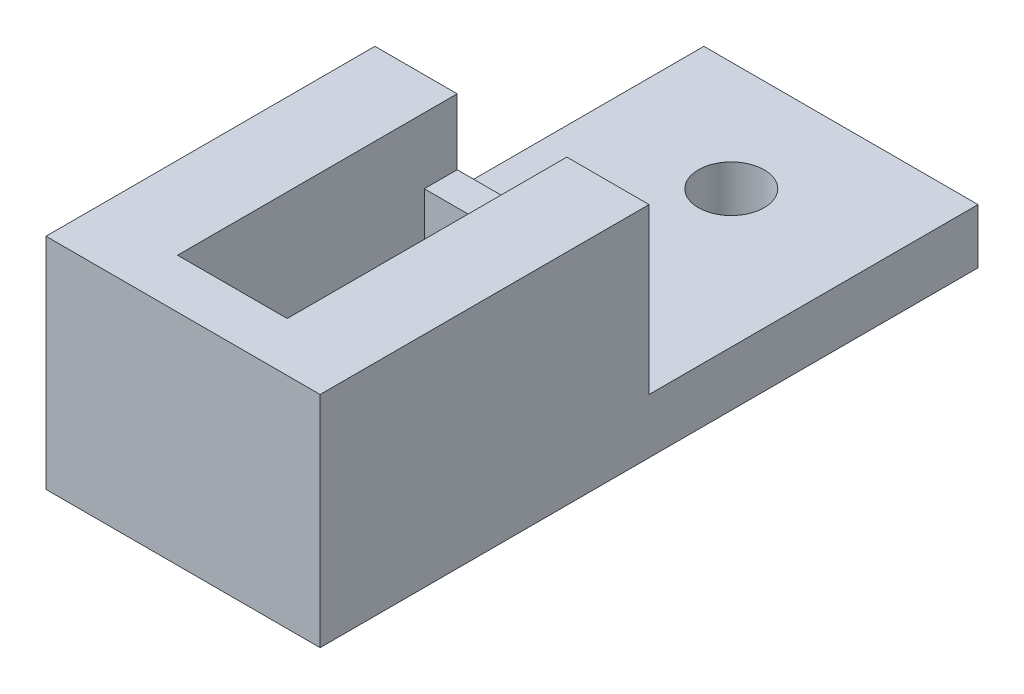
from build123d import *

# Parameters (mm, degrees)
SKETCH1_W           = 31.75
SKETCH1_H           = 76.2
BOSS_EXTRUDE1_DEPTH = 6.35
SKETCH2_R           = 3.81
CUT_EXTRUDE1_DEPTH  = 7.35
SKETCH3_W           = 31.75
SKETCH3_H           = 38.1
BOSS_EXTRUDE2_DEPTH = 19.05
SKETCH4_W           = 12.7
SKETCH4_H           = 38.1
CUT_EXTRUDE2_DEPTH  = 19.05
SKETCH5_W           = 12.7
SKETCH5_H           = 28.575
CUT_EXTRUDE3_DEPTH  = 7.35
SKETCH6_W           = 12.7
SKETCH6_H           = 3.81
BOSS_EXTRUDE3_DEPTH = 11.43
BOSS_EXTRUDE4_REACH = 24.225


with BuildPart() as part:
    # Sketch1 → Boss-Extrude1 (new body)
    with BuildSketch(Plane(origin=(0, 0, 0), x_dir=(1, 0, 0), z_dir=(0, 1, 0))):
        Rectangle(SKETCH1_W, SKETCH1_H)
    extrude(amount=BOSS_EXTRUDE1_DEPTH)

    # Sketch2 → Cut-Extrude1 (cut, through all)
    with BuildSketch(Plane(origin=(0, 6.35, 0), x_dir=(1, 0, 0), z_dir=(0, 1, 0))):
        with Locations((0, 25.4)):
            Circle(SKETCH2_R)
    extrude(amount=-CUT_EXTRUDE1_DEPTH, mode=Mode.SUBTRACT)

    # Sketch3 → Boss-Extrude2 (add)
    with BuildSketch(Plane(origin=(0, 6.35, 0), x_dir=(1, 0, 0), z_dir=(0, 1, 0))):
        with Locations((0, -19.05)):
            Rectangle(SKETCH3_W, SKETCH3_H)
    extrude(amount=BOSS_EXTRUDE2_DEPTH)

    # Sketch4 → Cut-Extrude2 (cut)
    with BuildSketch(Plane(origin=(0, 25.4, 0), x_dir=(1, 0, 0), z_dir=(0, 1, 0))):
        with Locations((0, -19.05)):
            Rectangle(SKETCH4_W, SKETCH4_H)
    extrude(amount=-CUT_EXTRUDE2_DEPTH, mode=Mode.SUBTRACT)

    # Sketch5 → Cut-Extrude3 (cut, through all)
    with BuildSketch(Plane(origin=(0, 6.35, 0), x_dir=(1, 0, 0), z_dir=(0, 1, 0))):
        with Locations((0, -18.0975)):
            Rectangle(SKETCH5_W, SKETCH5_H)
    extrude(amount=-CUT_EXTRUDE3_DEPTH, mode=Mode.SUBTRACT)

    # Sketch6 → Boss-Extrude3 (add)
    with BuildSketch(Plane(origin=(0, 6.35, 0), x_dir=(1, 0, 0), z_dir=(0, 1, 0))):
        with Locations((0, -1.905)):
            Rectangle(SKETCH6_W, SKETCH6_H)
    extrude(amount=BOSS_EXTRUDE3_DEPTH)

    # Sketch7 → Boss-Extrude4 (add, up to next)
    with BuildSketch(Plane(origin=(-6.35, 0, 0), x_dir=(0, 0, -1), z_dir=(1, 0, 0)), mode=Mode.PRIVATE) as boss_extrude4_sk1:
        Polygon((-32.385, 17.78), (-27.305, 17.78), (-27.305, 11.43), (-32.385, 11.43), (-32.385, 6.35), (-38.1, 6.35), (-38.1, 25.4), (-32.385, 25.4), align=None)
    boss_extrude4_tool1 = extrude(boss_extrude4_sk1.sketch, amount=BOSS_EXTRUDE4_REACH, mode=Mode.PRIVATE) - part.part
    add(boss_extrude4_tool1.solids().sort_by_distance((-6.35, 15.584714, 34.008786))[0])


solid = part.part
